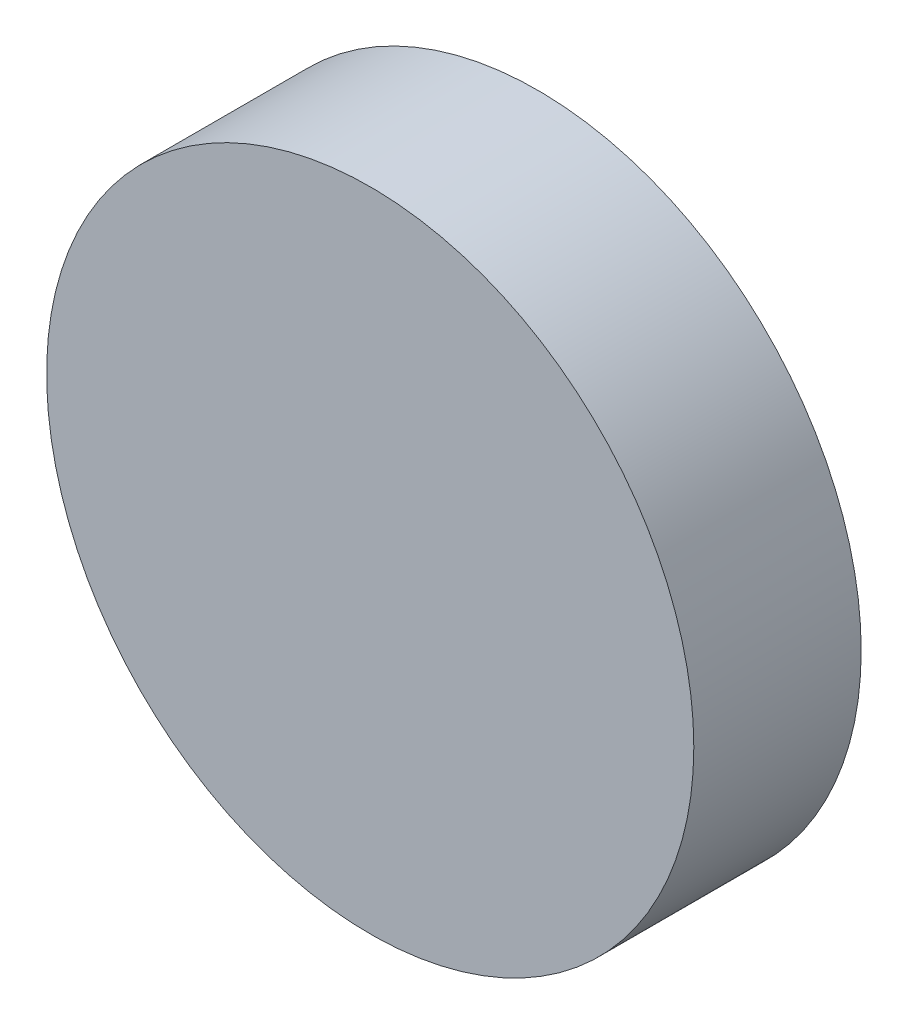
from build123d import *

# Parameters (mm, degrees)
SKETCH1_R           = 29
BOSS_EXTRUDE1_DEPTH = 15


with BuildPart() as part:
    # Sketch1 → Boss-Extrude1 (new body)
    with BuildSketch(Plane.XY):
        Circle(SKETCH1_R)
    extrude(amount=BOSS_EXTRUDE1_DEPTH)


solid = part.part
